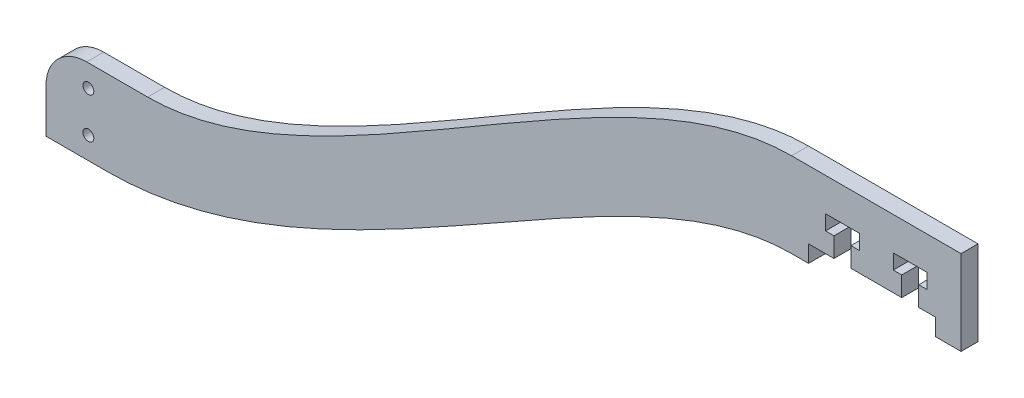
from build123d import *

# Parameters (mm, degrees)
SKETCH1_R           = 1.016
BOSS_EXTRUDE1_DEPTH = 3.175


with BuildPart() as part:
    # Sketch1 → Boss-Extrude1 (new body)
    with BuildSketch(Plane.XY):
        with BuildLine():
            Line((0, 0), (3.175, 0))
            Line((3.175, 0), (3.175, 3.175))
            Line((3.175, 3.175), (7.9375, 3.175))
            Line((7.9375, 3.175), (7.9375, 6.858))
            Line((7.9375, 6.858), (6.35, 6.858))
            Line((6.35, 6.858), (6.35, 9.652))
            Line((6.35, 9.652), (12.7, 9.652))
            Line((12.7, 9.652), (12.7, 6.858))
            Line((12.7, 6.858), (11.1125, 6.858))
            Line((11.1125, 6.858), (11.1125, 3.175))
            Line((11.1125, 3.175), (20.6375, 3.175))
            Line((20.6375, 3.175), (20.6375, 6.858))
            Line((20.6375, 6.858), (19.05, 6.858))
            Line((19.05, 6.858), (19.05, 9.652))
            Line((19.05, 9.652), (25.4, 9.652))
            Line((25.4, 9.652), (25.4, 6.858))
            Line((25.4, 6.858), (23.8125, 6.858))
            Line((23.8125, 6.858), (23.8125, 3.175))
            Line((23.8125, 3.175), (26.9875, 3.175))
            Line((26.9875, 3.175), (26.9875, 0))
            Line((26.9875, 0), (31.75, 0))
            Line((31.75, 0), (31.75, 15.875))
            Line((31.75, 15.875), (0, 15.875))
            add(Edge.make_bspline(
                [(-120.65, -34.925), (-86.994673616, -34.925), (-33.403901093, 15.875), (0, 15.875)],
                knots=[0, 0, 0, 0, 1, 1, 1, 1], degree=3))
            Line((-120.65, -34.925), (-132.08, -34.925))
            ThreePointArc((-132.08, -34.925), (-137.468153673, -37.156846327), (-139.7, -42.545))
            Line((-139.7, -42.545), (-139.7, -50.8))
            Line((-139.7, -50.8), (-128.27, -50.8))
            add(Edge.make_bspline(
                [(-128.27, -50.8), (-84.724287152, -50.8), (-32.997851809, 0), (0, 0)],
                knots=[0, 0, 0, 0, 1, 1, 1, 1], degree=3))
        make_face()
        with Locations((-131.7625, -39.0525)):
            Circle(SKETCH1_R, mode=Mode.SUBTRACT)
        with Locations((-131.7625, -46.6725)):
            Circle(SKETCH1_R, mode=Mode.SUBTRACT)
    extrude(amount=BOSS_EXTRUDE1_DEPTH)


solid = part.part
